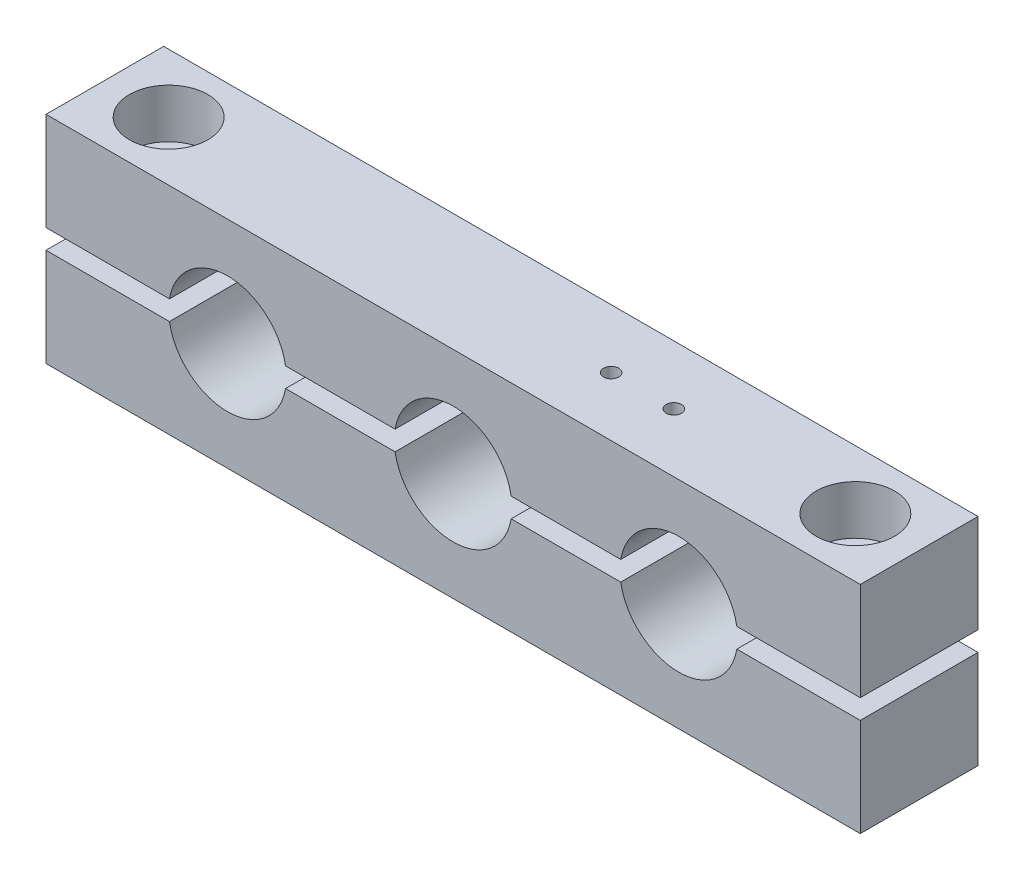
from build123d import *

# Parameters (mm, degrees)
SKETCH1_W           = 83
SKETCH1_H           = 22
SKETCH1_R           = 6
BOSS_EXTRUDE1_DEPTH = 12
SKETCH2_R           = 2.1
CUT_EXTRUDE1_DEPTH  = 23
SKETCH3_R           = 4
CUT_EXTRUDE2_DEPTH  = 5
SKETCH4_W           = 96.23839679
SKETCH4_H           = 2
CUT_EXTRUDE3_DEPTH  = 13
SKETCH5_R           = 0.78
CUT_EXTRUDE4_DEPTH  = 8


with BuildPart() as part:
    # Sketch1 → Boss-Extrude1 (new body)
    with BuildSketch(Plane.XY):
        Rectangle(SKETCH1_W, SKETCH1_H)
        Circle(SKETCH1_R, mode=Mode.SUBTRACT)
        with Locations((-23, 0)):
            Circle(SKETCH1_R, mode=Mode.SUBTRACT)
        with Locations((23, 0)):
            Circle(SKETCH1_R, mode=Mode.SUBTRACT)
    extrude(amount=BOSS_EXTRUDE1_DEPTH)

    # Sketch2 → Cut-Extrude1 (cut, through all)
    with BuildSketch(Plane(origin=(0, 11, 0), x_dir=(1, 0, 0), z_dir=(0, 1, 0))):
        with Locations((-35, -6)):
            Circle(SKETCH2_R)
        with Locations((35, -6)):
            Circle(SKETCH2_R)
    extrude(amount=-CUT_EXTRUDE1_DEPTH, mode=Mode.SUBTRACT)

    # Sketch3 → Cut-Extrude2 (cut)
    with BuildSketch(Plane(origin=(0, 11, 0), x_dir=(1, 0, 0), z_dir=(0, 1, 0))):
        with Locations((-35, -6)):
            Circle(SKETCH3_R)
        with Locations((35, -6)):
            Circle(SKETCH3_R)
    extrude(amount=-CUT_EXTRUDE2_DEPTH, mode=Mode.SUBTRACT)

    # Sketch4 → Cut-Extrude3 (cut, through all)
    with BuildSketch(Plane.XY.offset(12)):
        Rectangle(SKETCH4_W, SKETCH4_H)
    extrude(amount=-CUT_EXTRUDE3_DEPTH, mode=Mode.SUBTRACT)

    # Sketch5 → Cut-Extrude4 (cut)
    with BuildSketch(Plane(origin=(0, 11, 0), x_dir=(1, 0, 0), z_dir=(0, 1, 0))):
        with Locations((16.5, -6)):
            Circle(SKETCH5_R)
        with Locations((10.1, -6)):
            Circle(SKETCH5_R)
    extrude(amount=-CUT_EXTRUDE4_DEPTH, mode=Mode.SUBTRACT)


solid = part.part
